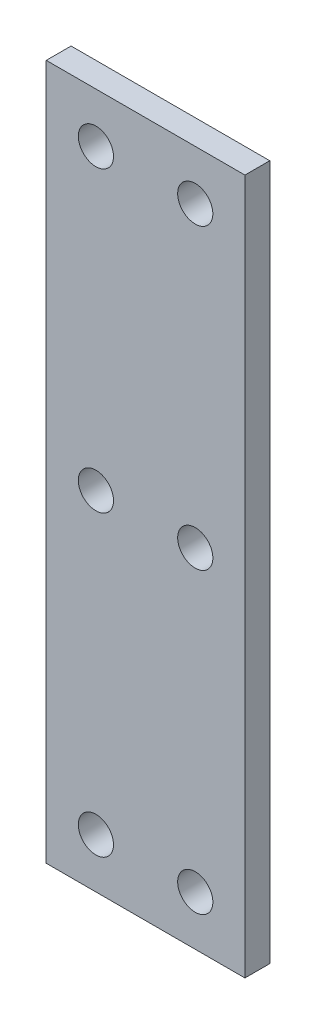
from build123d import *

# Parameters (mm, degrees)
SKETCH1_W           = 25.4
SKETCH1_H           = 88.9
SKETCH1_R           = 2.25
BOSS_EXTRUDE1_DEPTH = 3.175


with BuildPart() as part:
    # Sketch1 → Boss-Extrude1 (new body)
    with BuildSketch(Plane.XY):
        Rectangle(SKETCH1_W, SKETCH1_H)
        with Locations((-6.35, 38.1)):
            Circle(SKETCH1_R, mode=Mode.SUBTRACT)
        with Locations((-6.35, 0)):
            Circle(SKETCH1_R, mode=Mode.SUBTRACT)
        with Locations((-6.35, -38.1)):
            Circle(SKETCH1_R, mode=Mode.SUBTRACT)
        with Locations((6.35, -38.1)):
            Circle(SKETCH1_R, mode=Mode.SUBTRACT)
        with Locations((6.35, 0)):
            Circle(SKETCH1_R, mode=Mode.SUBTRACT)
        with Locations((6.35, 38.1)):
            Circle(SKETCH1_R, mode=Mode.SUBTRACT)
    extrude(amount=BOSS_EXTRUDE1_DEPTH)


solid = part.part
